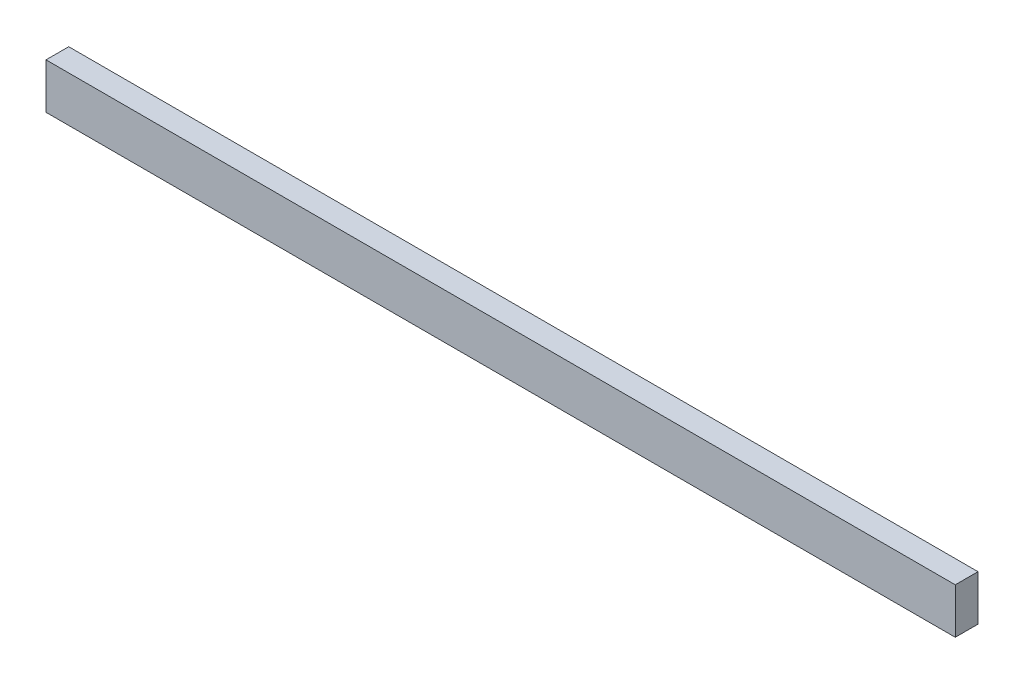
from build123d import *

# Parameters (mm, degrees)
SKETCH1_W           = 254
SKETCH1_H           = 12.7
BOSS_EXTRUDE1_DEPTH = 6.35


with BuildPart() as part:
    # Sketch1 → Boss-Extrude1 (new body)
    with BuildSketch(Plane.XY):
        Rectangle(SKETCH1_W, SKETCH1_H)
    extrude(amount=BOSS_EXTRUDE1_DEPTH)


solid = part.part
